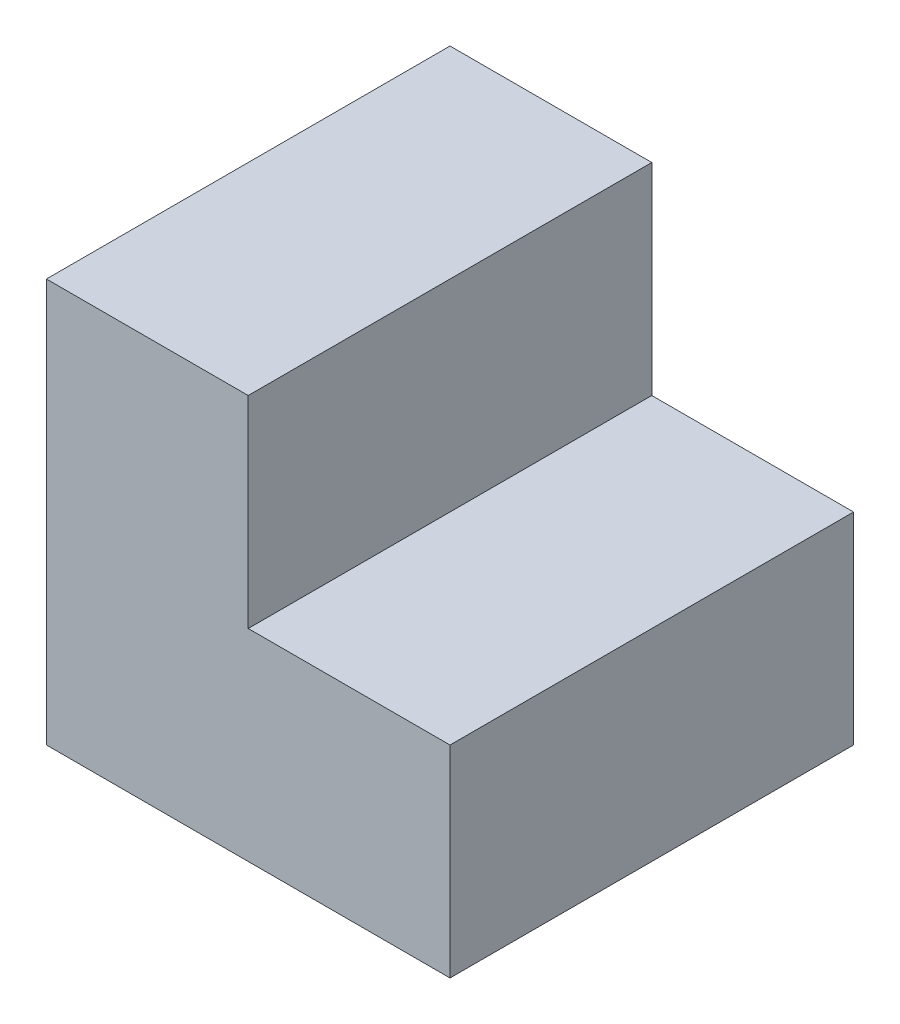
from build123d import *

# Parameters (mm, degrees)
BOSS_EXTRUDE2_DEPTH = 80


with BuildPart() as part:
    # Sketch1 → Boss-Extrude2 (new body)
    with BuildSketch(Plane.XY):
        Polygon((0, 0), (80, 0), (80, 40), (40, 40), (40, 80), (0, 80), align=None)
    extrude(amount=-BOSS_EXTRUDE2_DEPTH)


solid = part.part
